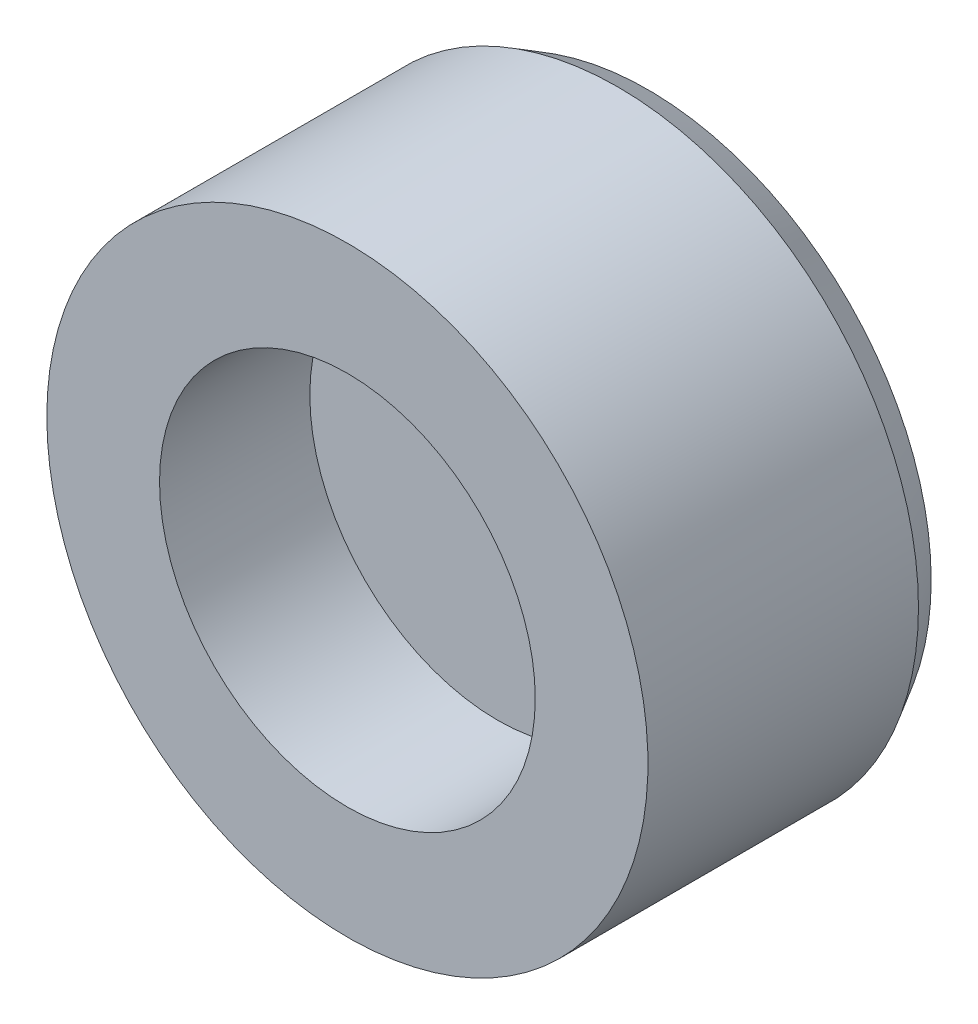
from build123d import *

# Parameters (mm, degrees)
SKETCH1_W          = 4
SKETCH1_H          = 4
CHAMFER1_SIZE      = 0.4
CHAMFER1_SIZE2     = 0.230940108
SKETCH2_R          = 2.5
CUT_EXTRUDE1_DEPTH = 2


with BuildPart() as part:
    # Sketch1 → Revolve1 (revolve)
    with BuildSketch(Plane(origin=(0, 0, 0), x_dir=(1, 0, 0), z_dir=(0, 1, 0))):
        with Locations((2, 0)):
            Rectangle(SKETCH1_W, SKETCH1_H)
    revolve(axis=Axis((0, 0, -141.429107981), (0, 0, 1)))

    # Chamfer1
    chamfer1_edges = [part.edges().sort_by_distance(p)[0] for p in [
        (-4, 0, -2),
    ]]
    chamfer1_side = [part.faces().sort_by_distance(p)[0] for p in [
        (-4, 0, 0),
    ]]
    chamfer(chamfer1_edges, length=CHAMFER1_SIZE, length2=CHAMFER1_SIZE2, reference=chamfer1_side[0])

    # Sketch2 → Cut-Extrude1 (cut)
    with BuildSketch(Plane.XY.offset(2)):
        Circle(SKETCH2_R)
    extrude(amount=-CUT_EXTRUDE1_DEPTH, mode=Mode.SUBTRACT)


solid = part.part
